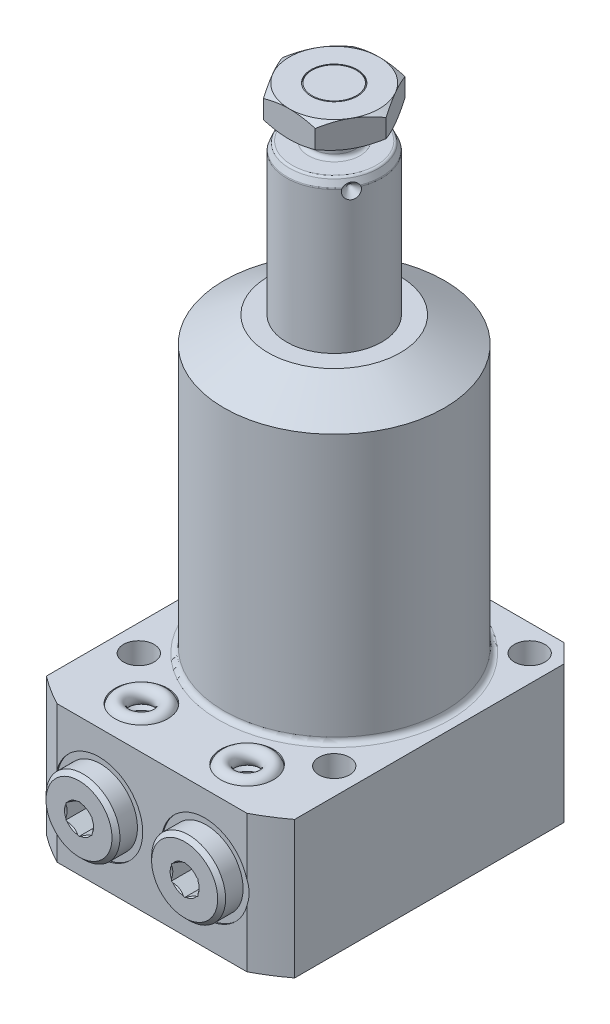
from build123d import *

# Parameters (mm, degrees)
FILLET2_R           = 0.75
FILLET3_R           = 0.5
SKETCH3_R           = 4.375
EXTRUDE3_DEPTH      = 5
CIRPATTERN1_COUNT   = 3
SKETCH7_OUTSIDE_W   = 112.276
SKETCH7_OUTSIDE_H   = 112.276
SKETCH7_OUTSIDE_W_2 = 47
SKETCH7_OUTSIDE_H_2 = 58
CUT_EXTRUDE5_DEPTH  = 27
SKETCH8_R           = 2.9
CUT_EXTRUDE6_DEPTH  = 27
CIRPATTERN2_COUNT   = 4
CHAMFER1_SIZE       = 3.5
FILLET5_R           = 1
CUT_EXTRUDE8_DEPTH  = 4.06
SKETCH16_R          = 1.5


with BuildPart() as part:
    # Sketch1 → Revolve2 (revolve)
    with BuildSketch(Plane.XY, mode=Mode.PRIVATE) as revolve2_sk:
        Polygon((9, 0), (9, 82.5), (8.300538513, 84), (4.125, 84), (4.125, 86), (4.935, 86.81), (4.935, 92.75), (4.185, 93.5), (0, 93.5), (0, 0), align=None)
    revolve(revolve2_sk.sketch.rotate(Axis((0, -3.075, 0), (0, 1, 0)), 90), axis=Axis((0, -3.075, 0), (0, 1, 0)))  # turned: the seam where the file's is

    # Fillet2
    fillet2_edges = [part.edges().sort_by_distance(p)[0] for p in [
        (0, 84, 4.125),
        (0, 86, 4.125),
    ]]
    fillet(fillet2_edges, radius=FILLET2_R)

    # Fillet3
    fillet3_edges = [part.edges().sort_by_distance(p)[0] for p in [
        (0, 82.5, 9),
        (0, 84, 8.300538513),
    ]]
    fillet(fillet3_edges, radius=FILLET3_R)

    # Sketch2 → Cut-Revolve1 (revolve, cut)
    with BuildSketch(Plane(origin=(0, 0, 0), x_dir=(0, 0, -1), z_dir=(1, 0, 0)), mode=Mode.PRIVATE) as cut_revolve1_sk:
        Polygon((7.5, 82), (9, 80.5), (9, 82), align=None)
    cut_revolve1 = revolve(cut_revolve1_sk.sketch.rotate(Axis((0, 82, -4.20155099), (0, 0, -1)), 90), axis=Axis((0, 82, -4.20155099), (0, 0, -1)), mode=Mode.SUBTRACT)  # turned: the seam where the file's is

    # Sketch3 → Extrude3 (add)
    with BuildSketch(Plane(origin=(0, 93.5, 0), x_dir=(1, 0, 0), z_dir=(0, 1, 0))):
        Polygon((9.814954576, 0), (4.907477288, 8.5), (-4.907477288, 8.5), (-9.814954576, 0), (-4.907477288, -8.5), (4.907477288, -8.5), align=None)
        with Locations(Location((0, 0, 0), (0, 0, 270))):  # turned: the seam where the file's is
            Circle(SKETCH3_R, mode=Mode.SUBTRACT)
    extrude(amount=-EXTRUDE3_DEPTH)

    # CirPattern1: Cut-Revolve1 ×3 about axis
    cirpattern1_axis = Axis((0, -3.075, 0), (0, -1, 0))
    for i in range(1, CIRPATTERN1_COUNT):
        add(cut_revolve1.rotate(cirpattern1_axis, i * 360 / CIRPATTERN1_COUNT), mode=Mode.SUBTRACT)

    # Sketch4 → Cut-Revolve3 (revolve, cut)
    with BuildSketch(Plane(origin=(0, 0, 0), x_dir=(0, 0, -1), z_dir=(1, 0, 0))):
        Polygon((8.5, 93.5), (11.5, 93.5), (11.5, 91.767949192), align=None)
        Polygon((11.5, 90.232050808), (8.5, 88.5), (11.5, 88.5), align=None)
    revolve(axis=Axis((0, -3.075, 0), (0, -1, 0)), mode=Mode.SUBTRACT)

    # Sketch6 → Revolve3 (revolve)
    with BuildSketch(Plane.XY, mode=Mode.PRIVATE) as revolve3_sk:
        Polygon((0, 55.5), (12.5, 55.5), (20.885, 50.658917993), (20.885, 0), (38.895, 0), (38.895, -26), (0, -26), align=None)
    revolve(revolve3_sk.sketch.rotate(Axis((0, 0, 0), (0, 1, 0)), 90), axis=Axis((0, 0, 0), (0, 1, 0)))  # turned: the seam where the file's is

    # Sketch7 outside → Cut-Extrude5 (cut, through all)
    with BuildSketch(Plane(origin=(0, 0, 0), x_dir=(-1, 0, 0), z_dir=(0, 1, 0))):
        Rectangle(SKETCH7_OUTSIDE_W, SKETCH7_OUTSIDE_H)
        with Locations((0, 5.5)):
            Rectangle(SKETCH7_OUTSIDE_W_2, SKETCH7_OUTSIDE_H_2, mode=Mode.SUBTRACT)
    extrude(amount=-CUT_EXTRUDE5_DEPTH, mode=Mode.SUBTRACT)

    # Sketch8 → Cut-Extrude6 (cut, through all)
    with BuildSketch(Plane(origin=(0, 0, 0), x_dir=(-1, 0, 0), z_dir=(0, 1, 0))):
        with Locations(Location((-18.5, 18.5, 0), (0, 0, 90))):  # turned: the seam where the file's is
            Circle(SKETCH8_R)
    cut_extrude6 = extrude(amount=-CUT_EXTRUDE6_DEPTH, mode=Mode.SUBTRACT)

    # CirPattern2: Cut-Extrude6 ×4 about axis
    cirpattern2_axis = Axis((0, 0, 0), (0, 1, 0))
    for i in range(1, CIRPATTERN2_COUNT):
        add(cut_extrude6.rotate(cirpattern2_axis, i * 360 / CIRPATTERN2_COUNT), mode=Mode.SUBTRACT)

    # Chamfer1
    chamfer1_edges = [part.edges().sort_by_distance(p)[0] for p in [
        (-23.5, -13, -23.5),
        (23.5, -13, -23.5),
    ]]
    chamfer(chamfer1_edges, length=CHAMFER1_SIZE)

    # Fillet5
    fillet5_edges = [part.edges().sort_by_distance(p)[0] for p in [
        (0, 0, 20.885),
    ]]
    fillet(fillet5_edges, radius=FILLET5_R)

    # Sketch11 → Cut-Revolve5 (revolve, cut)
    with BuildSketch(Plane.XZ.offset(13), mode=Mode.PRIVATE) as cut_revolve5_sk:
        Polygon((-18.25, 34.5), (-18.25, 34.25), (-15, 34.25), (-14.42, 33.67), (-14.42, 19.09), (-10, 19.09), (-10, 34.5), align=None)
    cut_revolve5 = revolve(cut_revolve5_sk.sketch.rotate(Axis((-10, -13, 42.971570338), (0, 0, -1)), 180), axis=Axis((-10, -13, 42.971570338), (0, 0, -1)), mode=Mode.SUBTRACT)  # turned: the seam where the file's is

    # Sketch13 → Cut-Revolve6 (revolve, cut)
    with BuildSketch(Plane.XY.offset(26.5)):
        Polygon((-12.5, -14), (-12.5, -23.125), (-13.125, -23.75), (-15, -23.75), (-15, -26), (-10, -26), (-10, -14), align=None)
    cut_revolve6 = revolve(axis=Axis((-10, 15.209907045, 26.5), (0, -1, 0)), mode=Mode.SUBTRACT)

    # Mirror4: Cut-Revolve6 across plane
    add(cut_revolve6.mirror(Plane(origin=(0, -13, 0), x_dir=(0, 0, 1), z_dir=(0, -1, 0))), mode=Mode.SUBTRACT)

    # Sketch14 → Revolve6 (revolve)
    with BuildSketch(Plane.XZ.offset(13)):
        Polygon((-12.75, 38.31), (-16.25, 38.31), (-17, 37.56), (-17, 34.25), (-14.125, 34.25), (-14.125, 31.80784845), (-10, 31.80784845), (-10, 31.80884845), (-12.5, 33.310999998), (-12.5, 38.06), align=None)
    revolve6 = revolve(axis=Axis((-10, -13, 32.588064048), (0, 0, 1)))

    # Sketch15 → Cut-Extrude8 (cut)
    with BuildSketch(Plane.XY.offset(38.31)):
        Polygon((-7.5, -14.443375673), (-7.5, -11.556624327), (-10, -10.113248654), (-12.5, -11.556624327), (-12.5, -14.443375673), (-10, -15.886751346), align=None)
    cut_extrude8 = extrude(amount=-CUT_EXTRUDE8_DEPTH, mode=Mode.SUBTRACT)

    # Mirror1: Cut-Revolve5, Cut-Revolve6, Revolve6, Cut-Extrude8 across plane
    add(cut_revolve5.mirror(Plane(origin=(0, 0, 0), x_dir=(0, 0, 1), z_dir=(1, 0, 0))), mode=Mode.SUBTRACT)
    add(cut_revolve6.mirror(Plane(origin=(0, 0, 0), x_dir=(0, 0, 1), z_dir=(1, 0, 0))), mode=Mode.SUBTRACT)
    add(revolve6.mirror(Plane(origin=(0, 0, 0), x_dir=(0, 0, 1), z_dir=(1, 0, 0))))
    add(cut_extrude8.mirror(Plane(origin=(0, 0, 0), x_dir=(0, 0, 1), z_dir=(1, 0, 0))), mode=Mode.SUBTRACT)

    # Mirror1 copy 1 sketch → Mirror1 copy 1 (revolve, cut)
    with BuildSketch(Plane(origin=(0, -26, 26.5), x_dir=(-1, 0, 0), z_dir=(0, 0, 1))):
        Polygon((-12.5, -14), (-12.5, -23.125), (-13.125, -23.75), (-15, -23.75), (-15, -26), (-10, -26), (-10, -14), align=None)
    revolve(axis=Axis((10, -41.209907045, 26.5), (0, 1, 0)), mode=Mode.SUBTRACT)


with BuildPart() as body_2:
    # Sketch16 → Revolve7 (revolve)
    with BuildSketch(Plane.XY.offset(26.5)):
        with Locations((-13.5, -25.25)):
            Circle(SKETCH16_R)
    revolve(axis=Axis((-10, 9.321927472, 26.5), (0, -1, 0)))


with BuildPart() as body_3:
    # Mirror3: mirrored copy
    add(body_2.part.mirror(Plane(origin=(0, 0, 0), x_dir=(0, 0, 1), z_dir=(1, 0, 0))))


with BuildPart() as body_4:
    # Mirror5: mirrored copy
    add(body_2.part.mirror(Plane(origin=(0, -13, 0), x_dir=(0, 0, 1), z_dir=(0, -1, 0))))


with BuildPart() as body_5:
    # Mirror5 2: mirrored copy
    add(body_3.part.mirror(Plane(origin=(0, -13, 0), x_dir=(0, 0, 1), z_dir=(0, -1, 0))))


solid = Compound([part.part, body_2.part, body_3.part, body_4.part, body_5.part])
